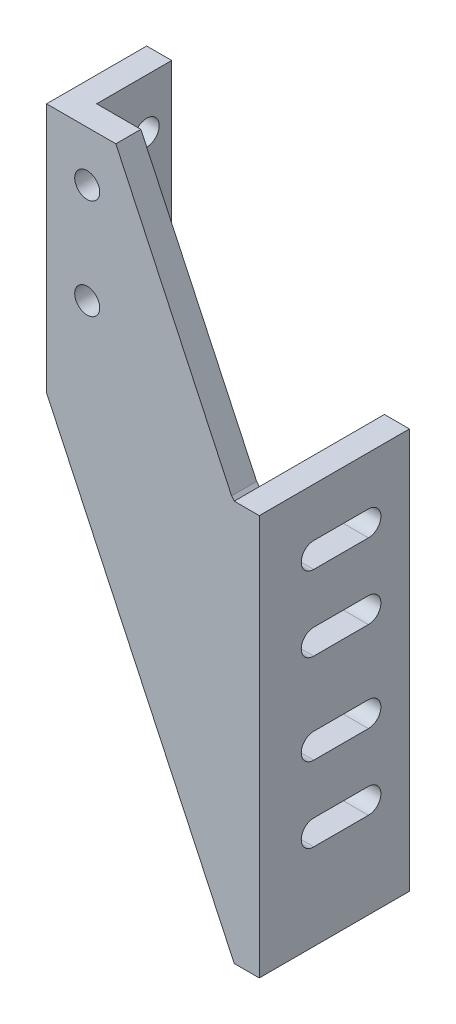
from build123d import *

# Parameters (mm, degrees)
EXTRUDE1_DEPTH          = 12.7
SKETCH2_W               = 12.7
SKETCH2_H               = 127
EXTRUDE2_DEPTH          = 38.1
SKETCH3_W               = 12.7
SKETCH3_H               = 203.2
EXTRUDE3_DEPTH          = 63.5
F_1_2_20_TAPPED_HOLE1_D = 12.7
F_1_2_20_TAPPED_HOLE2_D = 12.7
CUT_EXTRUDE1_REACH      = 109.933


with BuildPart() as part:
    # Sketch1 → Extrude1 (new body)
    with BuildSketch(Plane.XY):
        Polygon((1.34455174, -204.860398808), (1.34455174, -1.660398808), (-11.35544826, -1.660398808), (-12.7, 0), (-71.443804275, 125.347638028), (-106.588300915, 125.347638028), (-106.588300915, -1.652361972), (-11.35544826, -204.860398808), align=None)
    extrude(amount=EXTRUDE1_DEPTH)

    # Sketch2 → Extrude2 (add)
    with BuildSketch(Plane.XY):
        with Locations((-100.238300915, 61.847638028)):
            Rectangle(SKETCH2_W, SKETCH2_H)
    extrude(amount=-EXTRUDE2_DEPTH)

    # Sketch3 → Extrude3 (add)
    with BuildSketch(Plane.XY):
        with Locations((-5.00544826, -103.260398808)):
            Rectangle(SKETCH3_W, SKETCH3_H)
    extrude(amount=-EXTRUDE3_DEPTH)

    # 1/2-20 Tapped Hole1 (through all)
    with Locations(Plane(origin=(-106.588300915, 99.947638028, -25.4), x_dir=(0, -1, 0), z_dir=(-1, 0, 0))):
        with Locations((0, 0)):
            Hole(F_1_2_20_TAPPED_HOLE1_D / 2)

    # 1/2-20 Tapped Hole2 (through all)
    with Locations(Plane(origin=(-85.963500915, 99.947638028, 0), x_dir=(-1, 0, 0), z_dir=(0, 0, -1))):
        with Locations((0, 0), (0, -50.8)):
            Hole(F_1_2_20_TAPPED_HOLE2_D / 2)

    # Sketch6 → Cut-Extrude1 (cut, up to next)
    with BuildSketch(Plane(origin=(1.34455174, 0, 0), x_dir=(0, 0, -1), z_dir=(1, 0, 0)), mode=Mode.PRIVATE) as cut_extrude1_sk1:
        with BuildLine():
            Line((14.945063582, -26.425398808), (42.672, -26.425398808))
            ThreePointArc((42.672, -26.425398808), (49.022, -32.775398808), (42.672, -39.125398808))
            Line((42.672, -39.125398808), (14.945063582, -39.125398808))
            ThreePointArc((14.945063582, -39.125398808), (8.595063582, -32.775398808), (14.945063582, -26.425398808))
        make_face()
    cut_extrude1_tool1 = extrude(cut_extrude1_sk1.sketch, amount=-CUT_EXTRUDE1_REACH, mode=Mode.PRIVATE) & part.part
    add(cut_extrude1_tool1.solids().sort_by_distance((1.344552, -32.775399, -28.808532))[0], mode=Mode.SUBTRACT)
    # Sketch6 → Cut-Extrude1 (cut, up to next)
    with BuildSketch(Plane(origin=(1.34455174, 0, 0), x_dir=(0, 0, -1), z_dir=(1, 0, 0)), mode=Mode.PRIVATE) as cut_extrude1_sk2:
        with BuildLine():
            Line((14.945063582, -64.525398808), (42.672, -64.525398808))
            ThreePointArc((42.672, -64.525398808), (49.022, -70.875398808), (42.672, -77.225398808))
            Line((42.672, -77.225398808), (14.945063582, -77.225398808))
            ThreePointArc((14.945063582, -77.225398808), (8.595063582, -70.875398808), (14.945063582, -64.525398808))
        make_face()
    cut_extrude1_tool2 = extrude(cut_extrude1_sk2.sketch, amount=-CUT_EXTRUDE1_REACH, mode=Mode.PRIVATE) & part.part
    add(cut_extrude1_tool2.solids().sort_by_distance((1.344552, -70.875399, -28.808532))[0], mode=Mode.SUBTRACT)
    # Sketch6 → Cut-Extrude1 (cut, up to next)
    with BuildSketch(Plane(origin=(1.34455174, 0, 0), x_dir=(0, 0, -1), z_dir=(1, 0, 0)), mode=Mode.PRIVATE) as cut_extrude1_sk3:
        with BuildLine():
            Line((14.945063582, -110.245398808), (42.672, -110.245398808))
            ThreePointArc((42.672, -110.245398808), (49.022, -116.595398808), (42.672, -122.945398808))
            Line((42.672, -122.945398808), (14.945063582, -122.945398808))
            ThreePointArc((14.945063582, -122.945398808), (8.595063582, -116.595398808), (14.945063582, -110.245398808))
        make_face()
    cut_extrude1_tool3 = extrude(cut_extrude1_sk3.sketch, amount=-CUT_EXTRUDE1_REACH, mode=Mode.PRIVATE) & part.part
    add(cut_extrude1_tool3.solids().sort_by_distance((1.344552, -116.595399, -28.808532))[0], mode=Mode.SUBTRACT)
    # Sketch6 → Cut-Extrude1 (cut, up to next)
    with BuildSketch(Plane(origin=(1.34455174, 0, 0), x_dir=(0, 0, -1), z_dir=(1, 0, 0)), mode=Mode.PRIVATE) as cut_extrude1_sk4:
        with BuildLine():
            Line((14.945063582, -148.345398808), (42.672, -148.345398808))
            ThreePointArc((42.672, -148.345398808), (49.022, -154.695398808), (42.672, -161.045398808))
            Line((42.672, -161.045398808), (14.945063582, -161.045398808))
            ThreePointArc((14.945063582, -161.045398808), (8.595063582, -154.695398808), (14.945063582, -148.345398808))
        make_face()
    cut_extrude1_tool4 = extrude(cut_extrude1_sk4.sketch, amount=-CUT_EXTRUDE1_REACH, mode=Mode.PRIVATE) & part.part
    add(cut_extrude1_tool4.solids().sort_by_distance((1.344552, -154.695399, -28.808532))[0], mode=Mode.SUBTRACT)


solid = part.part
